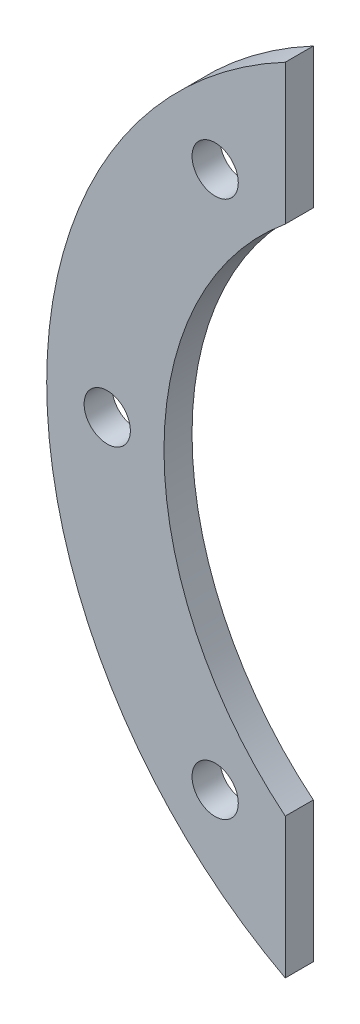
from build123d import *

# Parameters (mm, degrees)
SKETCH_1_R          = 1.65
EXTRUDE_1_DEPTH     = 2
SKETCH_2_OUTSIDE_W  = 35.044
SKETCH_2_OUTSIDE_H  = 96.312
SKETCH_2_OUTSIDE_R  = 32.015621187
CUT_EXTRUDE_1_DEPTH = 10


with BuildPart() as part:
    # 草图1 → 凸台-拉伸1 (new body)
    with BuildSketch(Plane.XY):
        with BuildLine():
            Line((10, 68.284271247), (10, 78.284271247))
            ThreePointArc((10, 78.284271247), (-6.350322366, 56.492864354), (0, 30))
            Line((0, 30), (0, 0))
            Line((0, 0), (10, 0))
            Line((10, 0), (10, 31.715728753))
            ThreePointArc((10, 31.715728753), (1.350167547, 50), (10, 68.284271247))
        make_face()
        with Locations((5, 5)):
            Circle(SKETCH_1_R, mode=Mode.SUBTRACT)
        with Locations((5, 17)):
            Circle(SKETCH_1_R, mode=Mode.SUBTRACT)
        with Locations((-2.697604364, 50)):
            Circle(SKETCH_1_R, mode=Mode.SUBTRACT)
        with Locations((5, 69.161348792)):
            Circle(SKETCH_1_R, mode=Mode.SUBTRACT)
        with Locations((5, 30.838651208)):
            Circle(SKETCH_1_R, mode=Mode.SUBTRACT)
    extrude(amount=EXTRUDE_1_DEPTH)

    # 草图2 outside → 切除-拉伸1 (cut)
    with BuildSketch(Plane.XY.offset(2)):
        with Locations((1.492, 39.142)):
            Rectangle(SKETCH_2_OUTSIDE_W, SKETCH_2_OUTSIDE_H)
        with Locations((25, 50)):
            Circle(SKETCH_2_OUTSIDE_R, mode=Mode.SUBTRACT)
    extrude(amount=-CUT_EXTRUDE_1_DEPTH, mode=Mode.SUBTRACT)


solid = part.part
